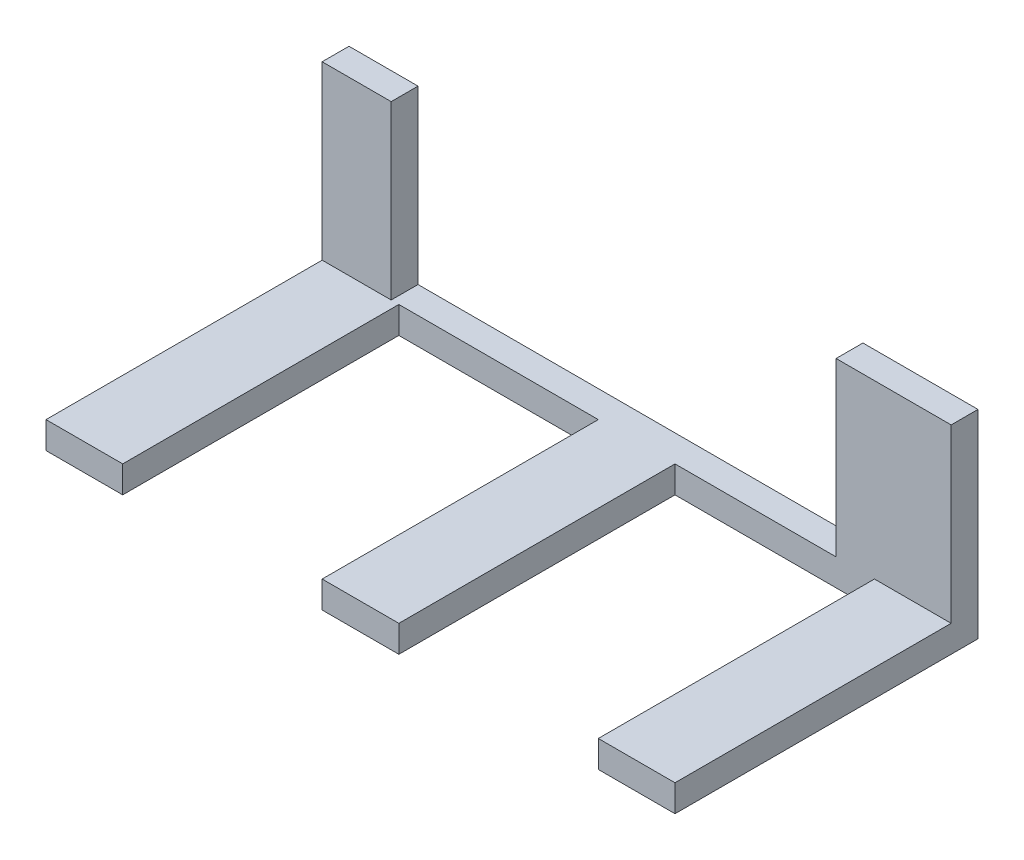
from build123d import *

# Parameters (mm, degrees)
CROQUIS1_W              = 82
CROQUIS1_H              = 3.5
SALIENTE_EXTRUIR1_DEPTH = 3.5
CROQUIS2_W              = 15
CROQUIS2_H              = 3.5
CROQUIS2_W_2            = 9
SALIENTE_EXTRUIR2_DEPTH = 22.4
CROQUIS3_W              = 10
CROQUIS3_H              = 3.5
SALIENTE_EXTRUIR3_DEPTH = 36


with BuildPart() as part:
    # Croquis1 → Saliente-Extruir1 (new body)
    with BuildSketch(Plane.XY):
        with Locations((-17.772529993, -26.701946472)):
            Rectangle(CROQUIS1_W, CROQUIS1_H)
    extrude(amount=SALIENTE_EXTRUIR1_DEPTH)

    # Croquis2 → Saliente-Extruir2 (add)
    with BuildSketch(Plane(origin=(0, -24.951946472, 0), x_dir=(1, 0, 0), z_dir=(0, 1, 0))):
        with Locations((15.727470007, -1.75)):
            Rectangle(CROQUIS2_W, CROQUIS2_H)
        with Locations((-54.272529993, -1.75)):
            Rectangle(CROQUIS2_W_2, CROQUIS2_H)
    extrude(amount=SALIENTE_EXTRUIR2_DEPTH)

    # Croquis3 → Saliente-Extruir3 (add)
    with BuildSketch(Plane.XY.offset(3.5)):
        with Locations((-53.772529993, -26.701946472)):
            Rectangle(CROQUIS3_W, CROQUIS3_H)
        with Locations((-17.772529993, -26.701946472)):
            Rectangle(CROQUIS3_W, CROQUIS3_H)
        with Locations((18.227470007, -26.701946472)):
            Rectangle(CROQUIS3_W, CROQUIS3_H)
    extrude(amount=SALIENTE_EXTRUIR3_DEPTH)


solid = part.part
